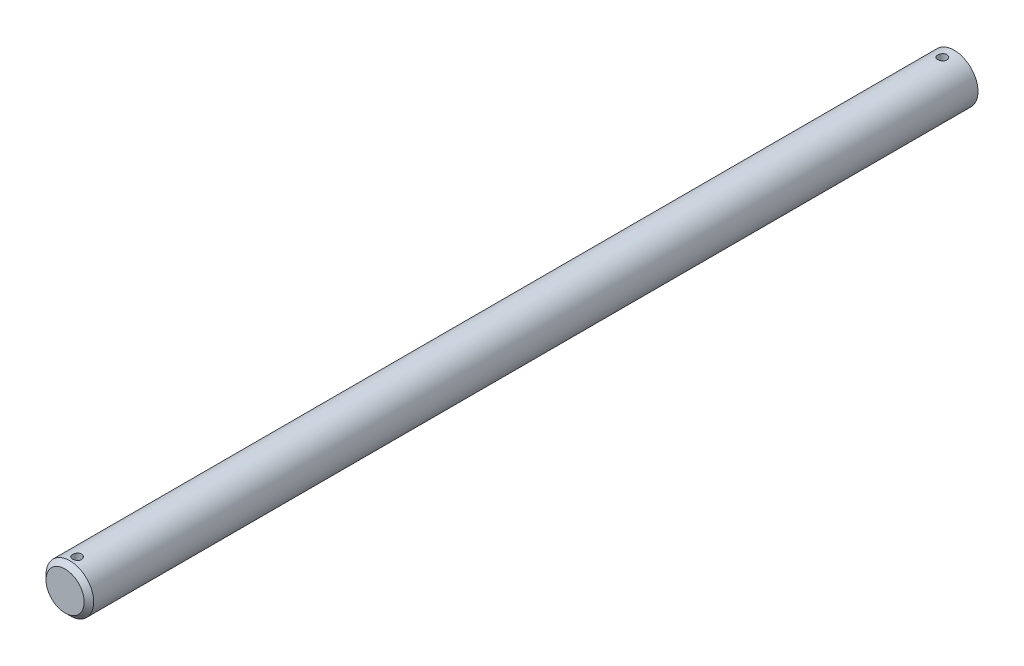
from build123d import *

# Parameters (mm, degrees)
SKETCH3_R               = 3.175
BOSS_EXTRUDE1_DEPTH     = 304.8
CHAMFER1_SIZE           = 0.635
CUT_EXTRUDE1_START      = -118.327050112
SKETCH4_R               = 3.175
CUT_EXTRUDE1_DEPTH      = 492.272949888
SKETCH5_R               = 0.5953125
CUT_EXTRUDE2_DEPTH      = 4.175
CUT_EXTRUDE2_DEPTH_BACK = 4.175


with BuildPart() as part:
    # Sketch3 → Boss-Extrude1 (new body, symmetric)
    with BuildSketch(Plane.XY):
        Circle(SKETCH3_R)
    extrude(amount=BOSS_EXTRUDE1_DEPTH, both=True)

    # Chamfer1
    chamfer1_edges = [part.edges().sort_by_distance(p)[0] for p in [
        (-3.175, 0, -304.8),
        (-3.175, 0, 304.8),
    ]]
    chamfer(chamfer1_edges, length=CHAMFER1_SIZE)

    # Sketch4 → Cut-Extrude1 (cut, through all)
    with BuildSketch(Plane.XY.offset(304.8).offset(CUT_EXTRUDE1_START)):
        Circle(SKETCH4_R)
    extrude(amount=-CUT_EXTRUDE1_DEPTH, mode=Mode.SUBTRACT)

    # Sketch5 → Cut-Extrude2 (cut, two sides)
    with BuildSketch(Plane(origin=(0, 0, 0), x_dir=(1, 0, 0), z_dir=(0, 1, 0))) as cut_extrude2_sk:
        with Locations((0, -188.060449888)):
            Circle(SKETCH5_R)
        with Locations((0, -303.2125)):
            Circle(SKETCH5_R)
    extrude(amount=CUT_EXTRUDE2_DEPTH, mode=Mode.SUBTRACT)
    extrude(cut_extrude2_sk.sketch, amount=-CUT_EXTRUDE2_DEPTH_BACK, mode=Mode.SUBTRACT)


solid = part.part
